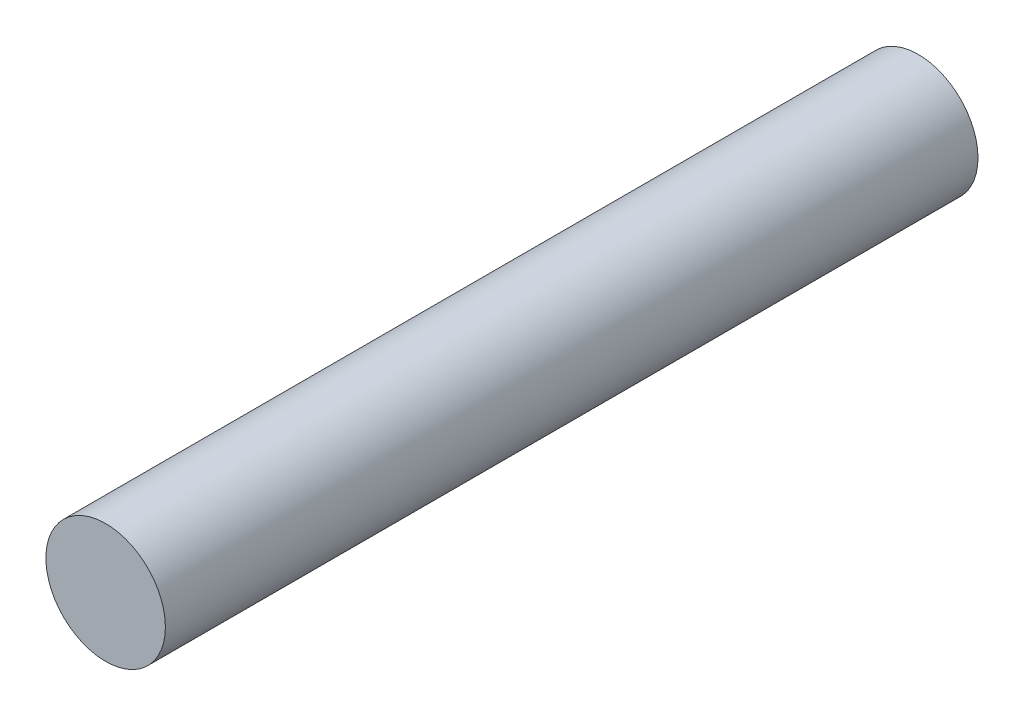
from build123d import *

# Parameters (mm, degrees)
SKETCH1_R           = 2.5
BOSS_EXTRUDE1_DEPTH = 34


with BuildPart() as part:
    # Sketch1 → Boss-Extrude1 (new body)
    with BuildSketch(Plane.XY):
        Circle(SKETCH1_R)
    extrude(amount=BOSS_EXTRUDE1_DEPTH)


solid = part.part
